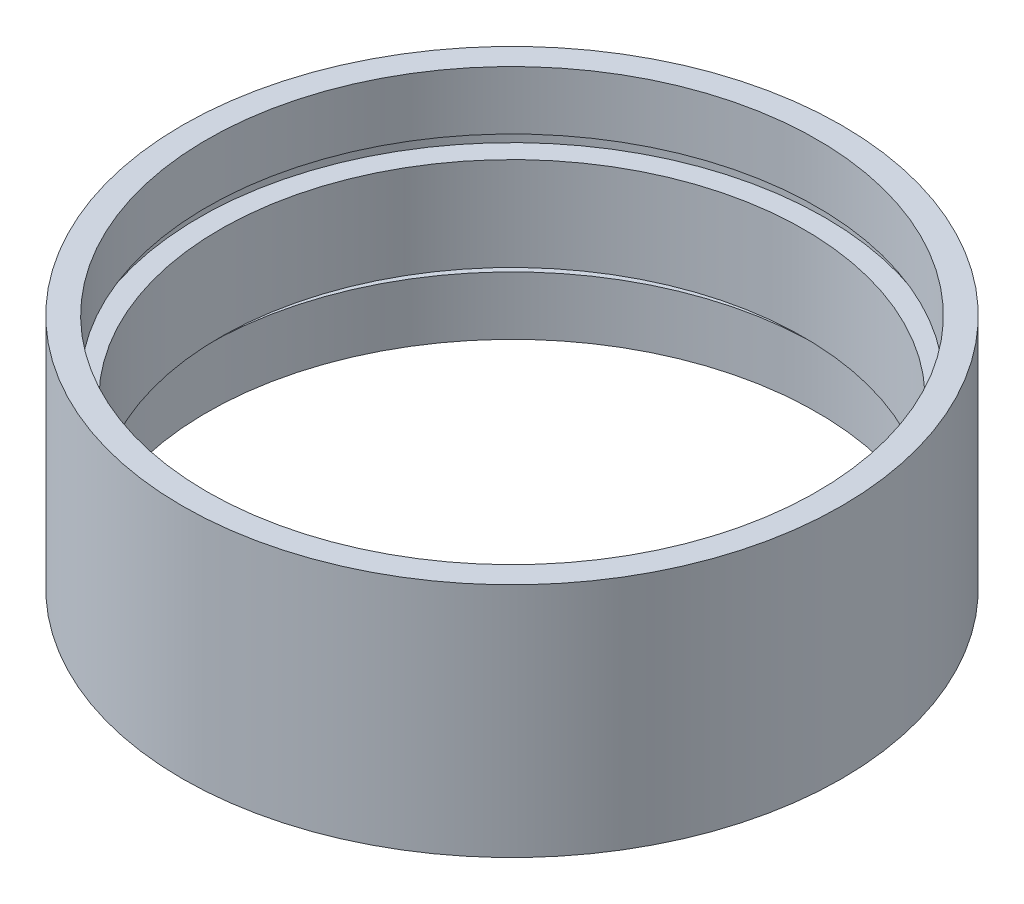
from build123d import *


with BuildPart() as part:
    # 草图1 → 旋转1 (revolve)
    with BuildSketch(Plane.XY, mode=Mode.PRIVATE) as revolve_1_sk:
        Polygon((25.4, 0), (25.4, 18.2), (23.5, 18.2), (23.5, 13.7), (24.1, 13.7), (24.1, 12.7), (22.5, 12.7), (22.5, 5.5), (24.1, 5.5), (24.1, 4.5), (23.5, 4.5), (23.5, 0), align=None)
    revolve(revolve_1_sk.sketch.rotate(Axis((0, 161.376166943, 0), (0, -1, 0)), 90), axis=Axis((0, 161.376166943, 0), (0, -1, 0)))  # turned: the seam where the file's is


solid = part.part
